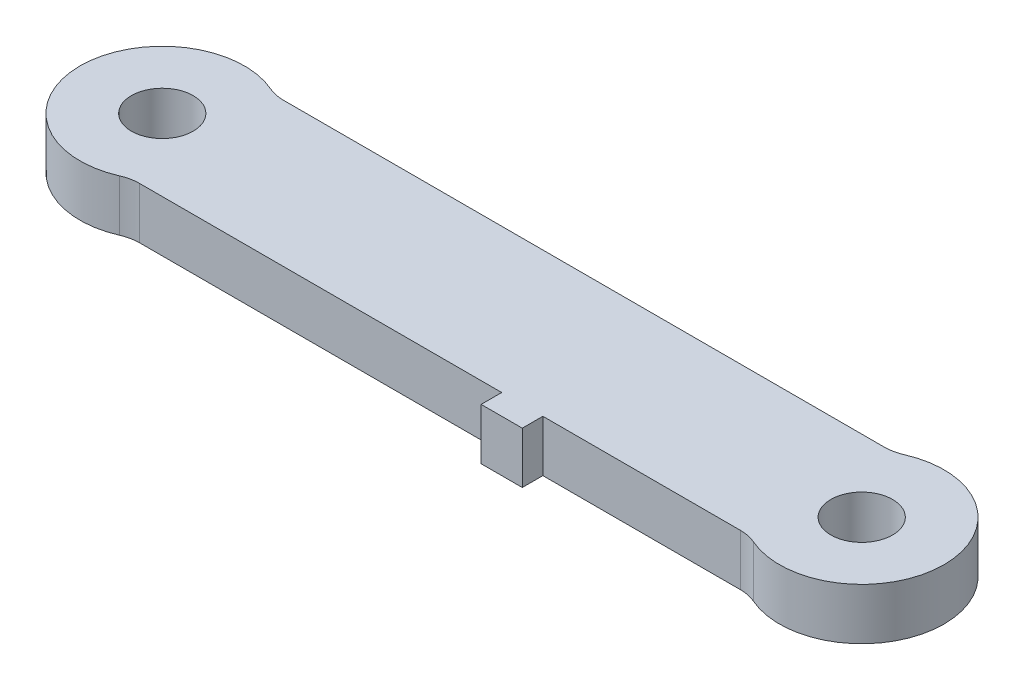
from build123d import *

# Parameters (mm, degrees)
SKETCH1_R           = 5.08
SKETCH1_R_2         = 1.905
BOSS_EXTRUDE1_DEPTH = 3.175
FILLET1_R           = 2.54
SKETCH2_W           = 2.54
SKETCH2_H           = 3.175
BOSS_EXTRUDE2_DEPTH = 1.27


with BuildPart() as part:
    # Sketch1 → Boss-Extrude1 (new body)
    with BuildSketch(Plane(origin=(0, 0, 0), x_dir=(1, 0, 0), z_dir=(0, 1, 0))):
        Circle(SKETCH1_R)
        Circle(SKETCH1_R_2, mode=Mode.SUBTRACT)
        with BuildLine():
            Line((40.720655575, 4.445), (2.459344425, 4.445))
            ThreePointArc((2.459344425, 4.445), (4.376063852, 2.580012628), (5.08, 0))
            ThreePointArc((5.08, 0), (4.376063852, -2.580012628), (2.459344425, -4.445))
            Line((2.459344425, -4.445), (40.720655575, -4.445))
            ThreePointArc((40.720655575, -4.445), (38.1, 0), (40.720655575, 4.445))
        make_face()
        with Locations((43.18, 0)):
            Circle(SKETCH1_R)
        with Locations((43.18, 0)):
            Circle(SKETCH1_R_2, mode=Mode.SUBTRACT)
    extrude(amount=BOSS_EXTRUDE1_DEPTH)

    # Fillet1
    fillet1_edges = [part.edges().sort_by_distance(p)[0] for p in [
        (2.459344425, 1.5875, -4.445),
        (40.720655575, 1.5875, -4.445),
        (40.720655575, 1.5875, 4.445),
        (2.459344425, 1.5875, 4.445),
    ]]
    fillet(fillet1_edges, radius=FILLET1_R)

    # Sketch2 → Boss-Extrude2 (add)
    with BuildSketch(Plane.XY.offset(4.445)):
        with Locations((26.67, 1.5875)):
            Rectangle(SKETCH2_W, SKETCH2_H)
    extrude(amount=BOSS_EXTRUDE2_DEPTH)


solid = part.part
